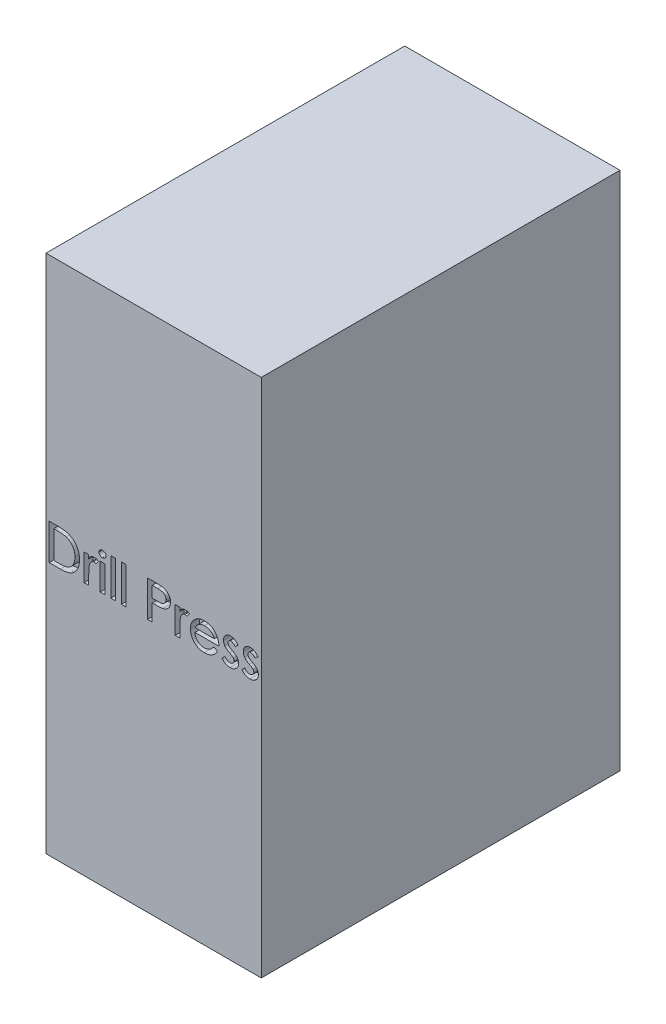
from build123d import *

# Parameters (mm, degrees)
SKETCH1_W           = 304.8
SKETCH1_H           = 508
BOSS_EXTRUDE1_DEPTH = 368.3
SKETCH3_W           = 6.512820513
SKETCH3_H           = 37.774358975
SKETCH3_W_2         = 6.512820512
SKETCH3_H_2         = 52.102564103
CUT_EXTRUDE2_DEPTH  = 12.7


with BuildPart() as part:
    # Sketch1 → Boss-Extrude1 (new, symmetric)
    with BuildSketch(Plane(origin=(0, 0, 0), x_dir=(1, 0, 0), z_dir=(0, 1, 0))):
        Rectangle(SKETCH1_W, SKETCH1_H)
    extrude(amount=BOSS_EXTRUDE1_DEPTH, both=True)

    # Sketch3 → Cut-Extrude2 (cut)
    with BuildSketch(Plane.XY.offset(254)):
        with BuildLine():
            Line((-147.913606609, -8.962248003), (-147.913606609, 41.837751997))
            Line((-147.913606609, 41.837751997), (-137.157276481, 41.837751997))
            add(Edge.make_bspline(
                [(-137.157276481, 41.837751997), (-136.251524455, 41.831438674), (-134.507480533, 41.819282241), (-131.98620406, 41.739560725), (-129.661017187, 41.602478145), (-127.526937512, 41.395851484), (-125.586109068, 41.152840361), (-123.839148556, 40.831340958), (-122.27937914, 40.484766183), (-121.324276308, 40.166046665), (-120.875225199, 40.01619751)],
                knots=[0, 0, 0, 0, 1.321377177, 2.544338591, 3.679698859, 4.71869479, 5.671952218, 6.531967125, 7.309789724, 8, 8, 8, 8], degree=3))
            add(Edge.make_bspline(
                [(-120.875225199, 40.01619751), (-120.246504354, 39.779287675), (-119.005573083, 39.311689335), (-117.247341258, 38.433946975), (-115.586235782, 37.470969925), (-114.042953471, 36.377875823), (-112.620441388, 35.161550662), (-111.294286932, 33.848560681), (-110.105408769, 32.400624766), (-109.016390087, 30.858607024), (-108.051474227, 29.220724154), (-107.216255929, 27.50848993), (-106.510843114, 25.725192129), (-105.930699182, 23.875370278), (-105.486084199, 21.955694419), (-105.157537289, 19.971387188), (-104.961222778, 17.917314029), (-104.939825233, 16.522978851), (-104.928991225, 15.816998792)],
                knots=[0, 0, 0, 0, 1.037989101, 2.048720264, 3.03347809, 4.003905725, 4.967380877, 5.923996735, 6.884742632, 7.859453364, 8.839691521, 9.819957728, 10.801471334, 11.80152298, 12.813966534, 13.844978706, 14.908869198, 16, 16, 16, 16], degree=3))
            add(Edge.make_bspline(
                [(-104.928991225, 15.816998792), (-104.938456233, 15.206088684), (-104.957153513, 13.999290213), (-105.115313102, 12.21197924), (-105.365615516, 10.474829818), (-105.723396727, 8.78895562), (-106.180863664, 7.156743133), (-106.744460466, 5.57360851), (-107.401482945, 4.037533743), (-108.167466958, 2.566016068), (-109.007104634, 1.163478166), (-109.925068884, -0.149879204), (-110.903070308, -1.374497628), (-111.943358241, -2.510499296), (-113.05560702, -3.551866105), (-114.238358109, -4.497801515), (-115.48461971, -5.357986322), (-116.806442497, -6.126485716), (-118.228527613, -6.809743899), (-119.777088066, -7.383220585), (-121.455186376, -7.868303426), (-123.261143674, -8.280735237), (-125.204446969, -8.574349194), (-127.275474655, -8.796567808), (-129.475397404, -8.946141219), (-130.986801846, -8.95677893), (-131.763846994, -8.962248003)],
                knots=[0, 0, 0, 0, 1.058131973, 2.090245403, 3.105765157, 4.096918797, 5.07359586, 6.040054961, 7.006085223, 7.965371986, 8.911666288, 9.835956746, 10.738988486, 11.624821356, 12.502036588, 13.375701924, 14.24610047, 15.122941669, 16.021834204, 16.975760622, 17.979893693, 19.046217526, 20.182340398, 21.382202726, 22.654134781, 24, 24, 24, 24], degree=3))
            Line((-131.763846994, -8.962248003), (-147.913606609, -8.962248003))
        make_face()
        with BuildLine():
            Line((-141.400786096, -3.100709541), (-136.984279686, -3.100709541))
            add(Edge.make_bspline(
                [(-136.984279686, -3.100709541), (-136.170113131, -3.097573768), (-134.605984662, -3.091549508), (-132.356962589, -3.024771967), (-130.303179802, -2.945040905), (-128.451224775, -2.797006641), (-126.797039704, -2.631795689), (-125.340590147, -2.418322257), (-124.075921644, -2.178263247), (-123.312781189, -1.952834445), (-122.961363019, -1.849026849)],
                knots=[0, 0, 0, 0, 1.383618687, 2.658126108, 3.823786659, 4.876093986, 5.815132222, 6.648351516, 7.377580062, 8, 8, 8, 8], degree=3))
            add(Edge.make_bspline(
                [(-122.961363019, -1.849026849), (-122.524541297, -1.692854728), (-121.661677931, -1.38436457), (-120.425299545, -0.810313125), (-119.260054894, -0.14814173), (-118.169851887, 0.608114475), (-117.145481958, 1.448511773), (-116.186129923, 2.372099721), (-115.308855001, 3.397869237), (-114.50823465, 4.505426537), (-113.782785461, 5.687228167), (-113.152253608, 6.939405568), (-112.618915255, 8.259423469), (-112.197875024, 9.644090706), (-111.857604363, 11.091648963), (-111.615482149, 12.604733488), (-111.472584639, 14.186037182), (-111.452186306, 15.260401881), (-111.441811737, 15.80682251)],
                knots=[0, 0, 0, 0, 0.982760408, 1.941267819, 2.884666843, 3.819923004, 4.749609063, 5.690155114, 6.638335438, 7.60609908, 8.583824457, 9.574050268, 10.573936541, 11.597196452, 12.638231748, 13.723193679, 14.842018967, 16, 16, 16, 16], degree=3))
            add(Edge.make_bspline(
                [(-111.441811737, 15.80682251), (-111.449988267, 16.380560729), (-111.466085472, 17.510084116), (-111.640786897, 19.170936502), (-111.884954616, 20.771342803), (-112.252704755, 22.306562805), (-112.73727685, 23.771834694), (-113.299581088, 25.18374816), (-113.989595415, 26.520547102), (-114.769990899, 27.790885151), (-115.641857168, 28.981520415), (-116.605568905, 30.07427316), (-117.643346575, 31.080767102), (-118.780331736, 31.970646261), (-119.98427293, 32.786315507), (-121.279921422, 33.481942634), (-122.653138602, 34.092676506), (-123.612999448, 34.41034583), (-124.101106609, 34.571886613)],
                knots=[0, 0, 0, 0, 1.129217777, 2.223100788, 3.284889252, 4.31516385, 5.326848226, 6.321524555, 7.304244934, 8.284784113, 9.254596696, 10.205833222, 11.15055266, 12.096616828, 13.045035565, 14.010353181, 14.988227444, 16, 16, 16, 16], degree=3))
            add(Edge.make_bspline(
                [(-124.101106609, 34.571886613), (-124.513738824, 34.685392925), (-125.390252887, 34.92650323), (-126.818901993, 35.204899827), (-128.428777611, 35.443548413), (-130.227324597, 35.648084297), (-132.206364341, 35.797340644), (-134.375117721, 35.89085892), (-136.725922706, 35.969422752), (-138.358000994, 35.973897539), (-139.202709173, 35.976213536)],
                knots=[0, 0, 0, 0, 0.675026783, 1.433893058, 2.294494921, 3.24250292, 4.28921909, 5.425097092, 6.667317884, 8, 8, 8, 8], degree=3))
            Line((-139.202709173, 35.976213536), (-141.400786096, 35.976213536))
            Line((-141.400786096, 35.976213536), (-141.400786096, -3.100709541))
        make_face(mode=Mode.SUBTRACT)
        with BuildLine():
            Line((-98.416170712, 28.812110972), (-91.903350199, 28.812110972))
            Line((-91.903350199, 28.812110972), (-91.903350199, 23.449210331))
            add(Edge.make_bspline(
                [(-91.903350199, 23.449210331), (-91.864051774, 23.694401604), (-91.787346822, 24.172980197), (-91.593862723, 24.860720227), (-91.326249283, 25.499232923), (-90.989876319, 26.089244796), (-90.590960268, 26.632996851), (-90.125452797, 27.127092246), (-89.595519343, 27.578451758), (-88.793775148, 28.094349226), (-87.741137478, 28.640006083), (-86.420359426, 29.113553691), (-85.068233542, 29.413547529), (-84.150548733, 29.446763001), (-83.691090584, 29.463393023)],
                knots=[0, 0, 0, 0, 0.801625561, 1.56465941, 2.301277113, 3.032414989, 3.753384473, 4.4742707, 5.220602463, 5.995500889, 7.548895402, 9.039144265, 10.517585467, 12, 12, 12, 12], degree=3))
            add(Edge.make_bspline(
                [(-83.691090584, 29.463393023), (-83.275532164, 29.438715661), (-82.402495193, 29.386871567), (-81.061470474, 29.041208929), (-79.649378773, 28.470712348), (-78.716669198, 27.960757591), (-78.226427122, 27.692719946)],
                knots=[0, 0, 0, 0, 0.858860638, 1.804360244, 2.845948385, 4, 4, 4, 4], degree=3))
            Line((-78.226427122, 27.692719946), (-81.309840584, 22.960748792))
            add(Edge.make_bspline(
                [(-81.309840584, 22.960748792), (-81.661555773, 23.06024219), (-82.304073857, 23.241998079), (-83.189725233, 23.427160945), (-83.890454361, 23.567493909), (-84.301259083, 23.591655631), (-84.474664302, 23.601854561)],
                knots=[0, 0, 0, 0, 1.354987806, 2.475310119, 3.356411532, 4, 4, 4, 4], degree=3))
            add(Edge.make_bspline(
                [(-84.474664302, 23.601854561), (-84.758801862, 23.58101822), (-85.356842549, 23.537162773), (-86.24895132, 23.19247309), (-87.164901524, 22.660671083), (-87.919526136, 22.06520602), (-88.524917722, 21.483172428), (-88.958043361, 20.949280376), (-89.378408934, 20.345048642), (-89.773036853, 19.664358413), (-90.13722657, 18.906637439), (-90.481650133, 18.080625126), (-90.812498866, 17.183200753), (-90.994913856, 16.550990311), (-91.089247635, 16.224050074)],
                knots=[0, 0, 0, 0, 0.965356871, 2.031842204, 3.216327082, 4.56533618, 5.292082419, 6.07124699, 6.900886396, 7.796081313, 8.746333432, 9.760722644, 10.841983902, 12, 12, 12, 12], degree=3))
            add(Edge.make_bspline(
                [(-91.089247635, 16.224050074), (-91.158127887, 15.953586345), (-91.312671047, 15.346760467), (-91.458167176, 14.316613221), (-91.604657375, 13.085666348), (-91.707705578, 11.648996137), (-91.802681385, 10.01070479), (-91.856704489, 8.16469545), (-91.90150288, 6.112439915), (-91.902715399, 4.674002499), (-91.903350199, 3.920925074)],
                knots=[0, 0, 0, 0, 0.541796663, 1.215601946, 2.018210726, 2.950106988, 4.012619945, 5.205915212, 6.537188929, 8, 8, 8, 8], degree=3))
            Line((-91.903350199, 3.920925074), (-91.903350199, -8.962248003))
            Line((-91.903350199, -8.962248003), (-98.416170712, -8.962248003))
            Line((-98.416170712, -8.962248003), (-98.416170712, 28.812110972))
        make_face()
        with BuildLine():
            add(Edge.make_bspline(
                [(-72.71088225, 43.791598151), (-72.319262115, 43.774448), (-71.563694209, 43.74135955), (-70.486805407, 43.475248542), (-69.524216323, 43.01760648), (-68.704194986, 42.387087766), (-68.024600793, 41.664883753), (-67.521443415, 40.884783216), (-67.218883163, 40.05772381), (-67.175945352, 39.492721974), (-67.15463225, 39.212271228)],
                knots=[0, 0, 0, 0, 1.180073081, 2.27676073, 3.320042968, 4.371717959, 5.377874923, 6.297457691, 7.154906711, 8, 8, 8, 8], degree=3))
            add(Edge.make_bspline(
                [(-67.15463225, 39.212271228), (-67.17598687, 38.935216603), (-67.219025383, 38.376835355), (-67.521388695, 37.559283131), (-68.028421999, 36.78963641), (-68.700592538, 36.06681515), (-69.527894251, 35.449111693), (-70.486292039, 34.98933841), (-71.563836869, 34.724071618), (-72.319310815, 34.690862255), (-72.71088225, 34.673649433)],
                knots=[0, 0, 0, 0, 0.838561902, 1.690053866, 2.604955955, 3.615478493, 4.665551833, 5.713360726, 6.814806749, 8, 8, 8, 8], degree=3))
            add(Edge.make_bspline(
                [(-72.71088225, 34.673649433), (-73.035238317, 34.686816735), (-73.667566895, 34.712486245), (-74.5715452, 34.987322513), (-75.413658278, 35.393193955), (-76.156887047, 35.975869808), (-76.784193391, 36.664113029), (-77.250145963, 37.447429403), (-77.521701932, 38.309417503), (-77.557164738, 38.90851643), (-77.575145071, 39.212271228)],
                knots=[0, 0, 0, 0, 1.050897616, 2.04871332, 3.044517726, 4.074156936, 5.096691018, 6.055190702, 7.01394389, 8, 8, 8, 8], degree=3))
            add(Edge.make_bspline(
                [(-77.575145071, 39.212271228), (-77.557915088, 39.522975404), (-77.524296794, 40.129206109), (-77.247488276, 40.999333633), (-76.787631142, 41.789443245), (-76.156897805, 42.479865037), (-75.410923944, 43.059508791), (-74.571695487, 43.482575788), (-73.663253029, 43.74970862), (-73.031577148, 43.777492554), (-72.71088225, 43.791598151)],
                knots=[0, 0, 0, 0, 1.003476519, 1.957934027, 2.921620235, 3.939572868, 4.964598795, 5.960849032, 6.964745478, 8, 8, 8, 8], degree=3))
        make_face()
        with Locations((-72.364888661, 9.924931485)):
            Rectangle(SKETCH3_W, SKETCH3_H)
        with Locations((-57.385401481, 17.089034049)):
            Rectangle(SKETCH3_W_2, SKETCH3_H_2)
        with Locations((-42.405914302, 17.089034049)):
            Rectangle(SKETCH3_W, SKETCH3_H_2)
        with BuildLine():
            Line((-8.539247635, 41.837751997), (1.871088904, 41.837751997))
            add(Edge.make_bspline(
                [(1.871088904, 41.837751997), (2.559724036, 41.837376842), (3.87946358, 41.836657872), (5.772111229, 41.787938069), (7.48916883, 41.745888843), (9.033173436, 41.665066635), (10.400609721, 41.554355702), (11.591968568, 41.42417291), (12.608529156, 41.277753229), (13.221594857, 41.145378164), (13.502579288, 41.084707126)],
                knots=[0, 0, 0, 0, 1.415450773, 2.712650385, 3.891531898, 4.945867971, 5.890285756, 6.71109784, 7.409261617, 8, 8, 8, 8], degree=3))
            add(Edge.make_bspline(
                [(13.502579288, 41.084707126), (13.898131482, 40.982988643), (14.678434715, 40.782329256), (15.793907219, 40.368710915), (16.852339938, 39.898718935), (17.850119189, 39.364087161), (18.777053057, 38.746616127), (19.653139668, 38.075743517), (20.451431917, 37.317537543), (21.19927864, 36.508780457), (21.855443662, 35.6309996), (22.443369417, 34.713896433), (22.93067045, 33.744150288), (23.33114945, 32.725368292), (23.644218367, 31.662862161), (23.869413357, 30.553246588), (24.004730594, 29.398954794), (24.018063945, 28.612347579), (24.024854929, 28.211710331)],
                knots=[0, 0, 0, 0, 1.085641105, 2.141637125, 3.15936318, 4.164535163, 5.147931294, 6.118832473, 7.09541784, 8.072503165, 9.045079613, 10.006206652, 10.966486436, 11.926469503, 12.914201526, 13.908586125, 14.934794539, 16, 16, 16, 16], degree=3))
            add(Edge.make_bspline(
                [(24.024854929, 28.211710331), (24.017914955, 27.811091749), (24.004230679, 27.021150102), (23.869767946, 25.85995779), (23.644368877, 24.748037131), (23.340488916, 23.68047601), (22.941123231, 22.663913765), (22.463914297, 21.689768222), (21.887060209, 20.769076223), (21.228513249, 19.895447181), (20.48482581, 19.082306906), (19.666775982, 18.332741749), (18.763610754, 17.659842571), (17.784593134, 17.051531525), (16.733134528, 16.497141551), (15.598657168, 16.020305327), (14.386222504, 15.613995449), (13.544765494, 15.397949353), (13.11588057, 15.287832126)],
                knots=[0, 0, 0, 0, 1.042501879, 2.055610221, 3.037454288, 3.993184118, 4.940927036, 5.876790881, 6.812738028, 7.76458517, 8.720845088, 9.677105007, 10.648370915, 11.647960469, 12.67482723, 13.739162042, 14.847666245, 16, 16, 16, 16], degree=3))
            add(Edge.make_bspline(
                [(13.11588057, 15.287832126), (12.801112421, 15.219588124), (12.114452203, 15.070715244), (10.974980878, 14.915802353), (9.647264183, 14.788888564), (8.127105781, 14.678471215), (6.420736787, 14.585719655), (4.520588466, 14.530506876), (2.430994505, 14.485954256), (0.972213215, 14.484607401), (0.212354929, 14.483905844)],
                knots=[0, 0, 0, 0, 0.596754895, 1.30180848, 2.129432098, 3.068723067, 4.126429569, 5.296393252, 6.591729958, 8, 8, 8, 8], degree=3))
            Line((0.212354929, 14.483905844), (-2.026427122, 14.483905844))
            Line((-2.026427122, 14.483905844), (-2.026427122, -8.962248003))
            Line((-2.026427122, -8.962248003), (-8.539247635, -8.962248003))
            Line((-8.539247635, -8.962248003), (-8.539247635, 41.837751997))
        make_face()
        with BuildLine():
            Line((-2.026427122, 35.976213536), (-2.026427122, 20.325091741))
            Line((-2.026427122, 20.325091741), (5.300495955, 20.243681485))
            add(Edge.make_bspline(
                [(5.300495955, 20.243681485), (5.714346897, 20.249138658), (6.511707346, 20.259652913), (7.662360786, 20.296159639), (8.720717579, 20.370357096), (9.688822121, 20.456892207), (10.568630103, 20.578214838), (11.356180699, 20.729631354), (12.058189121, 20.899756009), (12.860945747, 21.167229625), (13.759506393, 21.5848685), (14.714774515, 22.222099042), (15.55681043, 22.984179807), (16.252205109, 23.881147383), (16.811829947, 24.869429149), (17.227813215, 25.925719909), (17.463267229, 27.048063131), (17.495640967, 27.813786308), (17.512034416, 28.201534049)],
                knots=[0, 0, 0, 0, 1.196816259, 2.305888068, 3.328295896, 4.264290022, 5.116006351, 5.89509982, 6.582615619, 7.202969204, 8.339503699, 9.435837163, 10.511976311, 11.608836183, 12.702577786, 13.786378287, 14.879063815, 16, 16, 16, 16], degree=3))
            add(Edge.make_bspline(
                [(17.512034416, 28.201534049), (17.495522549, 28.575750387), (17.46277188, 29.317994422), (17.226087085, 30.409646522), (16.809911835, 31.445112337), (16.249375483, 32.419511377), (15.568218508, 33.310126707), (14.761355666, 34.076276101), (13.848210278, 34.702433574), (12.995718806, 35.103476371), (12.235591499, 35.364467601), (11.565648565, 35.517781731), (10.808817738, 35.661128313), (9.960399313, 35.784016658), (9.019603977, 35.872645756), (7.987565819, 35.929496523), (6.868026201, 35.974048016), (6.090904931, 35.975473174), (5.687194673, 35.976213536)],
                knots=[0, 0, 0, 0, 1.113934591, 2.209447376, 3.306634974, 4.424089692, 5.547326231, 6.633252657, 7.723023745, 8.829884498, 9.427152571, 10.113060991, 10.873719268, 11.720735618, 12.664423995, 13.686322671, 14.798057257, 16, 16, 16, 16], degree=3))
            Line((5.687194673, 35.976213536), (-2.026427122, 35.976213536))
        make_face(mode=Mode.SUBTRACT)
        with BuildLine():
            Line((30.537675442, 28.812110972), (37.050495955, 28.812110972))
            Line((37.050495955, 28.812110972), (37.050495955, 23.449210331))
            add(Edge.make_bspline(
                [(37.050495955, 23.449210331), (37.08979438, 23.694401604), (37.166499332, 24.172980197), (37.35998343, 24.860720227), (37.62759687, 25.499232923), (37.963969834, 26.089244796), (38.362885886, 26.632996851), (38.828393357, 27.127092246), (39.358326811, 27.578451758), (40.160071005, 28.094349226), (41.212708676, 28.640006083), (42.533486728, 29.113553691), (43.885612612, 29.413547529), (44.803297421, 29.446763001), (45.26275557, 29.463393023)],
                knots=[0, 0, 0, 0, 0.801625561, 1.56465941, 2.301277113, 3.032414989, 3.753384473, 4.4742707, 5.220602463, 5.995500889, 7.548895402, 9.039144265, 10.517585467, 12, 12, 12, 12], degree=3))
            add(Edge.make_bspline(
                [(45.26275557, 29.463393023), (45.678313989, 29.438715661), (46.551350961, 29.386871567), (47.892375679, 29.041208929), (49.304467381, 28.470712348), (50.237176956, 27.960757591), (50.727419032, 27.692719946)],
                knots=[0, 0, 0, 0, 0.858860638, 1.804360244, 2.845948385, 4, 4, 4, 4], degree=3))
            Line((50.727419032, 27.692719946), (47.64400557, 22.960748792))
            add(Edge.make_bspline(
                [(47.64400557, 22.960748792), (47.29229038, 23.06024219), (46.649772297, 23.241998079), (45.764120921, 23.427160945), (45.063391793, 23.567493909), (44.652587071, 23.591655631), (44.479181852, 23.601854561)],
                knots=[0, 0, 0, 0, 1.354987806, 2.475310119, 3.356411532, 4, 4, 4, 4], degree=3))
            add(Edge.make_bspline(
                [(44.479181852, 23.601854561), (44.195044292, 23.58101822), (43.597003605, 23.537162773), (42.704894834, 23.19247309), (41.78894463, 22.660671083), (41.034320018, 22.06520602), (40.428928431, 21.483172428), (39.995802793, 20.949280376), (39.575437219, 20.345048642), (39.180809301, 19.664358413), (38.816619584, 18.906637439), (38.472196021, 18.080625126), (38.141347288, 17.183200753), (37.958932298, 16.550990311), (37.864598519, 16.224050074)],
                knots=[0, 0, 0, 0, 0.965356871, 2.031842204, 3.216327082, 4.56533618, 5.292082419, 6.07124699, 6.900886396, 7.796081313, 8.746333432, 9.760722644, 10.841983902, 12, 12, 12, 12], degree=3))
            add(Edge.make_bspline(
                [(37.864598519, 16.224050074), (37.795718267, 15.953586345), (37.641175107, 15.346760467), (37.495678977, 14.316613221), (37.349188779, 13.085666348), (37.246140576, 11.648996137), (37.151164769, 10.01070479), (37.097141665, 8.16469545), (37.052343274, 6.112439915), (37.051130755, 4.674002499), (37.050495955, 3.920925074)],
                knots=[0, 0, 0, 0, 0.541796663, 1.215601946, 2.018210726, 2.950106988, 4.012619945, 5.205915212, 6.537188929, 8, 8, 8, 8], degree=3))
            Line((37.050495955, 3.920925074), (37.050495955, -8.962248003))
            Line((37.050495955, -8.962248003), (30.537675442, -8.962248003))
            Line((30.537675442, -8.962248003), (30.537675442, 28.812110972))
        make_face()
        with BuildLine():
            Line((85.031665827, 4.063393023), (90.45562416, 1.4684411))
            add(Edge.make_bspline(
                [(90.45562416, 1.4684411), (90.112715276, 0.845247373), (89.444930742, -0.368366951), (88.30544428, -2.0442293), (87.068813232, -3.518056468), (85.747057277, -4.806160003), (84.323686399, -5.90823587), (82.824319293, -6.885959262), (81.217154512, -7.705775238), (79.522819351, -8.4065268), (77.71907257, -8.945781146), (75.808134856, -9.328875213), (73.78610126, -9.567516479), (72.400181557, -9.597948293), (71.690560057, -9.613530054)],
                knots=[0, 0, 0, 0, 1.110387997, 2.162381809, 3.158716456, 4.110235088, 5.03849693, 5.965639636, 6.901458115, 7.851707839, 8.825366416, 9.836184406, 10.892078622, 12, 12, 12, 12], degree=3))
            add(Edge.make_bspline(
                [(71.690560057, -9.613530054), (70.939866473, -9.598064437), (69.473491456, -9.567854517), (67.342046096, -9.270900201), (65.330828972, -8.821531417), (63.447125732, -8.170704102), (61.698207167, -7.31590794), (60.063204527, -6.295257928), (58.561333477, -5.077032581), (57.206936059, -3.681746101), (56.0038226, -2.174819708), (54.928555939, -0.615621314), (54.049066215, 1.011492543), (53.306248338, 2.675116836), (52.734451102, 4.393194254), (52.329327874, 6.158193082), (52.074920838, 7.973853265), (52.045087571, 9.201577757), (52.029983134, 9.823168664)],
                knots=[0, 0, 0, 0, 1.164566152, 2.274817246, 3.333639364, 4.359360714, 5.360157823, 6.349126428, 7.344925074, 8.35392925, 9.361228562, 10.335284257, 11.289572886, 12.22779236, 13.160187688, 14.095091993, 15.035554391, 16, 16, 16, 16], degree=3))
            add(Edge.make_bspline(
                [(52.029983134, 9.823168664), (52.043207978, 10.403923666), (52.069439132, 11.555837056), (52.293165829, 13.257043768), (52.634225175, 14.913196044), (53.125513593, 16.517522587), (53.761341555, 18.072847094), (54.536938353, 19.581332874), (55.452833289, 21.042558129), (56.160522616, 21.958892775), (56.517723519, 22.421405844)],
                knots=[0, 0, 0, 0, 1.021096707, 2.025320431, 3.012923591, 3.992437812, 4.971861174, 5.964497656, 6.972595394, 8, 8, 8, 8], degree=3))
            add(Edge.make_bspline(
                [(56.517723519, 22.421405844), (57.000769183, 22.98257954), (57.952870397, 24.088674051), (59.575437461, 25.527334375), (61.314305842, 26.751411435), (63.180932557, 27.739523153), (65.161477999, 28.524617958), (67.267251915, 29.067433026), (69.492032896, 29.400485773), (71.014341833, 29.442117163), (71.792322878, 29.463393023)],
                knots=[0, 0, 0, 0, 1.018725525, 2.007946416, 2.977291296, 3.940674949, 4.909614547, 5.904411593, 6.929042575, 8, 8, 8, 8], degree=3))
            add(Edge.make_bspline(
                [(71.792322878, 29.463393023), (72.631484549, 29.444057141), (74.269835472, 29.406306418), (76.653329977, 29.049039046), (78.90147065, 28.484711685), (81.00861285, 27.676737598), (82.979016608, 26.640643838), (84.812156266, 25.380660834), (86.511531972, 23.889392981), (87.494526139, 22.733005127), (87.992963904, 22.146646228)],
                knots=[0, 0, 0, 0, 1.092510559, 2.132980742, 3.131821249, 4.106721871, 5.065344059, 6.025034973, 6.998572742, 8, 8, 8, 8], degree=3))
            add(Edge.make_bspline(
                [(87.992963904, 22.146646228), (88.341952272, 21.692066644), (89.037692905, 20.785820144), (89.909315273, 19.300861233), (90.667390686, 17.741308379), (91.291887716, 16.086855248), (91.761481114, 14.339477111), (92.12470992, 12.511676429), (92.334159061, 10.594471642), (92.377319658, 9.287689783), (92.399294032, 8.622367382)],
                knots=[0, 0, 0, 0, 0.947891001, 1.889708495, 2.844047414, 3.816063809, 4.811874475, 5.836031954, 6.898258033, 8, 8, 8, 8], degree=3))
            Line((92.399294032, 8.622367382), (58.532627365, 8.622367382))
            add(Edge.make_bspline(
                [(58.532627365, 8.622367382), (58.550098558, 8.190628823), (58.584408012, 7.342792354), (58.800606512, 6.104577533), (59.100597084, 4.916796045), (59.520986051, 3.781291092), (60.053174694, 2.69734571), (60.695056973, 1.665670505), (61.456342101, 0.694103851), (62.315594586, -0.214629461), (63.25311685, -1.041432696), (64.243650575, -1.767863047), (65.27973704, -2.388652237), (66.367849337, -2.881325516), (67.497522761, -3.276684649), (68.67224058, -3.543638974), (69.890210259, -3.729990374), (70.719691883, -3.744580365), (71.141040827, -3.751991592)],
                knots=[0, 0, 0, 0, 1.056285998, 2.074305788, 3.068874036, 4.051103373, 5.031155672, 6.019259974, 7.018838325, 8.046424154, 9.075617995, 10.073437039, 11.048590896, 12.025474346, 12.991505956, 13.972050267, 14.969869311, 16, 16, 16, 16], degree=3))
            add(Edge.make_bspline(
                [(71.141040827, -3.751991592), (71.592772506, -3.743497616), (72.492432899, -3.72658117), (73.824390878, -3.551028794), (75.137296596, -3.304971038), (76.409022769, -2.932094828), (77.629942885, -2.49563562), (78.761924655, -1.974672686), (79.795036169, -1.395288565), (80.768868473, -0.725027155), (81.739049786, 0.11533071), (82.761157781, 1.195952892), (83.876466414, 2.535234748), (84.629035958, 3.530773149), (85.031665827, 4.063393023)],
                knots=[0, 0, 0, 0, 0.974501181, 1.940798391, 2.895710587, 3.855187413, 4.797895034, 5.692306932, 6.541458453, 7.351844759, 8.239729442, 9.306468335, 10.558942083, 12, 12, 12, 12], degree=3))
        make_face()
        with BuildLine():
            add(Edge.make_bspline(
                [(85.896649801, 14.483905844), (85.731615416, 14.904634428), (85.402466066, 15.743747686), (84.768765567, 16.934957229), (84.018433234, 18.04741683), (83.172457535, 19.098089807), (82.187682308, 20.064763152), (81.04821094, 20.927477672), (79.766606286, 21.709725621), (78.342500775, 22.365671706), (76.832156863, 22.912927029), (75.265544434, 23.313982832), (73.65858455, 23.55313668), (72.573299658, 23.585530105), (72.026377365, 23.601854561)],
                knots=[0, 0, 0, 0, 0.917468198, 1.829825112, 2.733739057, 3.639830069, 4.565591991, 5.528900948, 6.536885056, 7.609579627, 8.708054817, 9.795976896, 10.889296829, 12, 12, 12, 12], degree=3))
            add(Edge.make_bspline(
                [(72.026377365, 23.601854561), (71.608775269, 23.591319368), (70.78133165, 23.570444764), (69.558596364, 23.427003023), (68.37321895, 23.18336083), (67.225751353, 22.834571564), (66.117052737, 22.385388279), (65.040828, 21.842204185), (64.001107686, 21.203444586), (63.348828275, 20.707247452), (63.02036775, 20.457383408)],
                knots=[0, 0, 0, 0, 1.030056501, 2.040970785, 3.032161429, 4.011555994, 4.995123754, 5.979296403, 6.982458509, 8, 8, 8, 8], degree=3))
            add(Edge.make_bspline(
                [(63.02036775, 20.457383408), (62.6033004, 20.090242902), (61.749744518, 19.338865607), (60.690147607, 17.92846871), (59.736929867, 16.311455752), (59.25926347, 15.109061202), (59.010912622, 14.483905844)],
                knots=[0, 0, 0, 0, 0.913853049, 1.870260628, 2.892694598, 4, 4, 4, 4], degree=3))
            Line((59.010912622, 14.483905844), (85.896649801, 14.483905844))
        make_face(mode=Mode.SUBTRACT)
        with BuildLine():
            Line((119.763316468, 23.469562895), (115.601217109, 19.694162254))
            add(Edge.make_bspline(
                [(115.601217109, 19.694162254), (115.296579007, 20.003715935), (114.710261189, 20.599494458), (113.8032498, 21.387446878), (112.937580067, 22.07131864), (112.092503844, 22.62214331), (111.276596714, 23.056856198), (110.488715941, 23.366053467), (109.728985489, 23.563433882), (109.228533996, 23.589334929), (108.986633775, 23.601854561)],
                knots=[0, 0, 0, 0, 1.323954473, 2.548132, 3.661338868, 4.685637623, 5.620299102, 6.475132344, 7.262933916, 8, 8, 8, 8], degree=3))
            add(Edge.make_bspline(
                [(108.986633775, 23.601854561), (108.774280107, 23.588831346), (108.344425852, 23.562469264), (107.720942313, 23.31883026), (107.123219568, 22.94027541), (106.550782362, 22.440141169), (106.050321914, 21.816383995), (105.692843852, 21.079089085), (105.470106551, 20.253138396), (105.447113928, 19.671925491), (105.435111339, 19.368521228)],
                knots=[0, 0, 0, 0, 0.832490187, 1.685157841, 2.595972223, 3.607628721, 4.662023247, 5.718189086, 6.808851023, 8, 8, 8, 8], degree=3))
            add(Edge.make_bspline(
                [(105.435111339, 19.368521228), (105.44569555, 19.095831432), (105.466327408, 18.564275725), (105.660704804, 17.803639668), (105.948105767, 17.090358093), (106.249957618, 16.683300296), (106.401858134, 16.478457126)],
                knots=[0, 0, 0, 0, 1.051456026, 2.049608974, 3.018507243, 4, 4, 4, 4], degree=3))
            add(Edge.make_bspline(
                [(106.401858134, 16.478457126), (106.665633839, 16.18551422), (107.241567833, 15.545895883), (108.360832761, 14.687287014), (109.726919846, 13.778849185), (110.755857304, 13.210772277), (111.306826083, 12.906582126)],
                knots=[0, 0, 0, 0, 0.773884963, 1.689718389, 2.762905336, 4, 4, 4, 4], degree=3))
            add(Edge.make_bspline(
                [(111.306826083, 12.906582126), (111.742529554, 12.66843859), (112.579995189, 12.210702904), (113.761532753, 11.50868334), (114.827108694, 10.82271959), (115.783675091, 10.158417433), (116.619221537, 9.498155156), (117.334222171, 8.853974871), (117.947375616, 8.237081529), (118.281588666, 7.801528631), (118.440399801, 7.594562895)],
                knots=[0, 0, 0, 0, 1.33001518, 2.556422155, 3.680542608, 4.724184501, 5.674971885, 6.530695486, 7.30181686, 8, 8, 8, 8], degree=3))
            add(Edge.make_bspline(
                [(118.440399801, 7.594562895), (118.743773389, 7.121031247), (119.337202291, 6.194756263), (119.957137804, 4.692103449), (120.344917374, 3.153644502), (120.391362257, 2.111792497), (120.414598519, 1.590556485)],
                knots=[0, 0, 0, 0, 1.049962625, 2.053831286, 3.026336549, 4, 4, 4, 4], degree=3))
            add(Edge.make_bspline(
                [(120.414598519, 1.590556485), (120.406107356, 1.220142466), (120.389350904, 0.48916784), (120.217608075, -0.584133372), (119.955966744, -1.622723242), (119.573206387, -2.622814579), (119.095539667, -3.592161628), (118.508815483, -4.526080188), (117.814794872, -5.423436495), (117.015551524, -6.269973705), (116.137911291, -7.047956735), (115.194493209, -7.739260732), (114.187606792, -8.319329307), (113.113803201, -8.787808757), (111.986760795, -9.173311703), (110.785343261, -9.414364726), (109.531135367, -9.589891011), (108.67183073, -9.605546049), (108.233588904, -9.613530054)],
                knots=[0, 0, 0, 0, 0.963489602, 1.901349341, 2.822262455, 3.747230613, 4.683134612, 5.631288318, 6.613293617, 7.631511985, 8.657397281, 9.662358437, 10.671075458, 11.675221639, 12.708377436, 13.76481686, 14.860065804, 16, 16, 16, 16], degree=3))
            add(Edge.make_bspline(
                [(108.233588904, -9.613530054), (107.696550513, -9.595340377), (106.62617467, -9.559086375), (105.042424145, -9.28453954), (103.491969978, -8.845560247), (101.98985165, -8.227308657), (100.555052885, -7.426354215), (99.238001789, -6.411729864), (98.010903901, -5.233758737), (97.319545049, -4.318540012), (96.968444673, -3.853754413)],
                knots=[0, 0, 0, 0, 0.979216887, 1.951685614, 2.923149898, 3.913640395, 4.908296688, 5.910698089, 6.938966812, 8, 8, 8, 8], degree=3))
            Line((96.968444673, -3.853754413), (100.804903006, 0.155700715))
            add(Edge.make_bspline(
                [(100.804903006, 0.155700715), (101.130038071, -0.153930006), (101.757203772, -0.751188774), (102.725395961, -1.543421939), (103.661354694, -2.219946496), (104.570236848, -2.777419727), (105.456396799, -3.208152469), (106.318251553, -3.51931079), (107.156404914, -3.713759235), (107.71026855, -3.739495873), (107.979181852, -3.751991592)],
                knots=[0, 0, 0, 0, 1.288506075, 2.485449601, 3.588003455, 4.601705531, 5.542438646, 6.411005369, 7.228507225, 8, 8, 8, 8], degree=3))
            add(Edge.make_bspline(
                [(107.979181852, -3.751991592), (108.377752522, -3.73180368), (109.155017467, -3.692434609), (110.277082059, -3.402192095), (111.300006735, -2.906233408), (112.19724597, -2.224043391), (112.945388181, -1.423351679), (113.503387237, -0.535559151), (113.835341319, 0.431594189), (113.879443591, 1.099612336), (113.901778006, 1.437912254)],
                knots=[0, 0, 0, 0, 1.096025125, 2.137392371, 3.164312155, 4.204088696, 5.221248568, 6.164137697, 7.070276657, 8, 8, 8, 8], degree=3))
            add(Edge.make_bspline(
                [(113.901778006, 1.437912254), (113.887964287, 1.714039174), (113.86079804, 2.257074138), (113.647495508, 3.046772877), (113.300107499, 3.794806056), (112.964226774, 4.235192986), (112.792563263, 4.460268023)],
                knots=[0, 0, 0, 0, 1.00762038, 1.981599971, 2.968426558, 4, 4, 4, 4], degree=3))
            add(Edge.make_bspline(
                [(112.792563263, 4.460268023), (112.682786929, 4.581165425), (112.442055345, 4.84628471), (111.997387188, 5.228521219), (111.461572579, 5.639008836), (110.835387949, 6.085403934), (110.099911178, 6.532852242), (109.277356101, 7.027137426), (108.348995205, 7.529889052), (107.697962859, 7.873362952), (107.358428647, 8.052495587)],
                knots=[0, 0, 0, 0, 0.598311898, 1.312054841, 2.145484848, 3.073753233, 4.129800786, 5.300877464, 6.592321185, 8, 8, 8, 8], degree=3))
            add(Edge.make_bspline(
                [(107.358428647, 8.052495587), (106.969877508, 8.266403516), (106.215864557, 8.681508072), (105.150986161, 9.336774339), (104.166928903, 9.970859798), (103.292000269, 10.622656794), (102.513677938, 11.278860668), (101.824877814, 11.924795139), (101.219329988, 12.564298185), (100.89184357, 13.021549166), (100.733669032, 13.242399433)],
                knots=[0, 0, 0, 0, 1.253912045, 2.433311408, 3.534624239, 4.562802555, 5.515759338, 6.411389838, 7.23270809, 8, 8, 8, 8], degree=3))
            add(Edge.make_bspline(
                [(100.733669032, 13.242399433), (100.452310855, 13.684994352), (99.891369462, 14.567392059), (99.347586904, 16.050572585), (98.978916382, 17.610188718), (98.941387663, 18.687851067), (98.922290827, 19.236229561)],
                knots=[0, 0, 0, 0, 0.987528248, 1.968826629, 2.966418566, 4, 4, 4, 4], degree=3))
            add(Edge.make_bspline(
                [(98.922290827, 19.236229561), (98.927474998, 19.596456377), (98.937642485, 20.302953456), (99.095063655, 21.331874527), (99.296539998, 22.321606063), (99.622867897, 23.257426578), (100.011489129, 24.162108031), (100.519867364, 25.001481124), (101.091538898, 25.809836622), (101.759605043, 26.554743088), (102.500654648, 27.229979551), (103.28062072, 27.836140286), (104.114590386, 28.340078029), (104.997190698, 28.745618673), (105.921284604, 29.077635619), (106.896459426, 29.292476934), (107.909779027, 29.447421075), (108.602698104, 29.457998341), (108.956104929, 29.463393023)],
                knots=[0, 0, 0, 0, 1.077691122, 2.11362841, 3.112019185, 4.098344371, 5.07626173, 6.055497571, 7.031037172, 8.038433535, 9.045112416, 10.030652415, 10.992446082, 11.956062447, 12.936088526, 13.926799257, 14.942613481, 16, 16, 16, 16], degree=3))
            add(Edge.make_bspline(
                [(108.956104929, 29.463393023), (109.412155581, 29.446388713), (110.333059321, 29.412051886), (111.706930884, 29.107906367), (113.076447636, 28.638391382), (114.440093641, 27.98010241), (115.786166346, 27.122328399), (117.134151662, 26.087256439), (118.478691764, 24.864979747), (119.326004436, 23.944590798), (119.763316468, 23.469562895)],
                knots=[0, 0, 0, 0, 0.858658356, 1.733890061, 2.639692681, 3.583355905, 4.58026951, 5.642917418, 6.783470838, 8, 8, 8, 8], degree=3))
        make_face()
        with BuildLine():
            Line((147.768444673, 23.469562895), (143.606345314, 19.694162254))
            add(Edge.make_bspline(
                [(143.606345314, 19.694162254), (143.301707212, 20.003715935), (142.715389395, 20.599494458), (141.808378005, 21.387446878), (140.942708273, 22.07131864), (140.097632049, 22.62214331), (139.281724919, 23.056856198), (138.493844146, 23.366053467), (137.734113694, 23.563433882), (137.233662201, 23.589334929), (136.991761981, 23.601854561)],
                knots=[0, 0, 0, 0, 1.323954473, 2.548132, 3.661338868, 4.685637623, 5.620299102, 6.475132344, 7.262933916, 8, 8, 8, 8], degree=3))
            add(Edge.make_bspline(
                [(136.991761981, 23.601854561), (136.779408312, 23.588831346), (136.349554057, 23.562469264), (135.726070518, 23.31883026), (135.128347773, 22.94027541), (134.555910567, 22.440141169), (134.055450119, 21.816383995), (133.697972057, 21.079089085), (133.475234756, 20.253138396), (133.452242134, 19.671925491), (133.440239545, 19.368521228)],
                knots=[0, 0, 0, 0, 0.832490187, 1.685157841, 2.595972223, 3.607628721, 4.662023247, 5.718189086, 6.808851023, 8, 8, 8, 8], degree=3))
            add(Edge.make_bspline(
                [(133.440239545, 19.368521228), (133.450823755, 19.095831432), (133.471455613, 18.564275725), (133.665833009, 17.803639668), (133.953233972, 17.090358093), (134.255085823, 16.683300296), (134.406986339, 16.478457126)],
                knots=[0, 0, 0, 0, 1.051456026, 2.049608974, 3.018507243, 4, 4, 4, 4], degree=3))
            add(Edge.make_bspline(
                [(134.406986339, 16.478457126), (134.670762044, 16.18551422), (135.246696038, 15.545895883), (136.365960966, 14.687287014), (137.732048051, 13.778849185), (138.760985509, 13.210772277), (139.311954288, 12.906582126)],
                knots=[0, 0, 0, 0, 0.773884963, 1.689718389, 2.762905336, 4, 4, 4, 4], degree=3))
            add(Edge.make_bspline(
                [(139.311954288, 12.906582126), (139.74765776, 12.66843859), (140.585123394, 12.210702904), (141.766660958, 11.50868334), (142.832236899, 10.82271959), (143.788803296, 10.158417433), (144.624349742, 9.498155156), (145.339350376, 8.853974871), (145.952503821, 8.237081529), (146.286716871, 7.801528631), (146.445528006, 7.594562895)],
                knots=[0, 0, 0, 0, 1.33001518, 2.556422155, 3.680542608, 4.724184501, 5.674971885, 6.530695486, 7.30181686, 8, 8, 8, 8], degree=3))
            add(Edge.make_bspline(
                [(146.445528006, 7.594562895), (146.748901595, 7.121031247), (147.342330496, 6.194756263), (147.96226601, 4.692103449), (148.350045579, 3.153644502), (148.396490462, 2.111792497), (148.419726724, 1.590556485)],
                knots=[0, 0, 0, 0, 1.049962625, 2.053831286, 3.026336549, 4, 4, 4, 4], degree=3))
            add(Edge.make_bspline(
                [(148.419726724, 1.590556485), (148.411235561, 1.220142466), (148.394479109, 0.48916784), (148.22273628, -0.584133372), (147.96109495, -1.622723242), (147.578334593, -2.622814579), (147.100667872, -3.592161628), (146.513943688, -4.526080188), (145.819923077, -5.423436495), (145.020679729, -6.269973705), (144.143039496, -7.047956735), (143.199621415, -7.739260732), (142.192734998, -8.319329307), (141.118931406, -8.787808757), (139.991889, -9.173311703), (138.790471466, -9.414364726), (137.536263572, -9.589891011), (136.676958935, -9.605546049), (136.238717109, -9.613530054)],
                knots=[0, 0, 0, 0, 0.963489602, 1.901349341, 2.822262455, 3.747230613, 4.683134612, 5.631288318, 6.613293617, 7.631511985, 8.657397281, 9.662358437, 10.671075458, 11.675221639, 12.708377436, 13.76481686, 14.860065804, 16, 16, 16, 16], degree=3))
            add(Edge.make_bspline(
                [(136.238717109, -9.613530054), (135.701678718, -9.595340377), (134.631302875, -9.559086375), (133.04755235, -9.28453954), (131.497098183, -8.845560247), (129.994979855, -8.227308657), (128.56018109, -7.426354215), (127.243129994, -6.411729864), (126.016032106, -5.233758737), (125.324673254, -4.318540012), (124.973572878, -3.853754413)],
                knots=[0, 0, 0, 0, 0.979216887, 1.951685614, 2.923149898, 3.913640395, 4.908296688, 5.910698089, 6.938966812, 8, 8, 8, 8], degree=3))
            Line((124.973572878, -3.853754413), (128.810031211, 0.155700715))
            add(Edge.make_bspline(
                [(128.810031211, 0.155700715), (129.135166276, -0.153930006), (129.762331977, -0.751188774), (130.730524166, -1.543421939), (131.666482899, -2.219946496), (132.575365053, -2.777419727), (133.461525004, -3.208152469), (134.323379759, -3.51931079), (135.16153312, -3.713759235), (135.715396755, -3.739495873), (135.984310057, -3.751991592)],
                knots=[0, 0, 0, 0, 1.288506075, 2.485449601, 3.588003455, 4.601705531, 5.542438646, 6.411005369, 7.228507225, 8, 8, 8, 8], degree=3))
            add(Edge.make_bspline(
                [(135.984310057, -3.751991592), (136.382880727, -3.73180368), (137.160145673, -3.692434609), (138.282210264, -3.402192095), (139.30513494, -2.906233408), (140.202374175, -2.224043391), (140.950516387, -1.423351679), (141.508515442, -0.535559151), (141.840469524, 0.431594189), (141.884571796, 1.099612336), (141.906906211, 1.437912254)],
                knots=[0, 0, 0, 0, 1.096025125, 2.137392371, 3.164312155, 4.204088696, 5.221248568, 6.164137697, 7.070276657, 8, 8, 8, 8], degree=3))
            add(Edge.make_bspline(
                [(141.906906211, 1.437912254), (141.893092493, 1.714039174), (141.865926245, 2.257074138), (141.652623713, 3.046772877), (141.305235704, 3.794806056), (140.969354979, 4.235192986), (140.797691468, 4.460268023)],
                knots=[0, 0, 0, 0, 1.00762038, 1.981599971, 2.968426558, 4, 4, 4, 4], degree=3))
            add(Edge.make_bspline(
                [(140.797691468, 4.460268023), (140.687915134, 4.581165425), (140.447183551, 4.84628471), (140.002515393, 5.228521219), (139.466700784, 5.639008836), (138.840516154, 6.085403934), (138.105039383, 6.532852242), (137.282484306, 7.027137426), (136.35412341, 7.529889052), (135.703091064, 7.873362952), (135.363556852, 8.052495587)],
                knots=[0, 0, 0, 0, 0.598311898, 1.312054841, 2.145484848, 3.073753233, 4.129800786, 5.300877464, 6.592321185, 8, 8, 8, 8], degree=3))
            add(Edge.make_bspline(
                [(135.363556852, 8.052495587), (134.975005713, 8.266403516), (134.220992762, 8.681508072), (133.156114366, 9.336774339), (132.172057109, 9.970859798), (131.297128474, 10.622656794), (130.518806144, 11.278860668), (129.830006019, 11.924795139), (129.224458193, 12.564298185), (128.896971775, 13.021549166), (128.738797237, 13.242399433)],
                knots=[0, 0, 0, 0, 1.253912045, 2.433311408, 3.534624239, 4.562802555, 5.515759338, 6.411389838, 7.23270809, 8, 8, 8, 8], degree=3))
            add(Edge.make_bspline(
                [(128.738797237, 13.242399433), (128.45743906, 13.684994352), (127.896497667, 14.567392059), (127.352715109, 16.050572585), (126.984044587, 17.610188718), (126.946515869, 18.687851067), (126.927419032, 19.236229561)],
                knots=[0, 0, 0, 0, 0.987528248, 1.968826629, 2.966418566, 4, 4, 4, 4], degree=3))
            add(Edge.make_bspline(
                [(126.927419032, 19.236229561), (126.932603203, 19.596456377), (126.94277069, 20.302953456), (127.100191861, 21.331874527), (127.301668203, 22.321606063), (127.627996102, 23.257426578), (128.016617334, 24.162108031), (128.524995569, 25.001481124), (129.096667103, 25.809836622), (129.764733248, 26.554743088), (130.505782854, 27.229979551), (131.285748925, 27.836140286), (132.119718591, 28.340078029), (133.002318903, 28.745618673), (133.926412809, 29.077635619), (134.901587631, 29.292476934), (135.914907232, 29.447421075), (136.60782631, 29.457998341), (136.961233134, 29.463393023)],
                knots=[0, 0, 0, 0, 1.077691122, 2.11362841, 3.112019185, 4.098344371, 5.07626173, 6.055497571, 7.031037172, 8.038433535, 9.045112416, 10.030652415, 10.992446082, 11.956062447, 12.936088526, 13.926799257, 14.942613481, 16, 16, 16, 16], degree=3))
            add(Edge.make_bspline(
                [(136.961233134, 29.463393023), (137.417283786, 29.446388713), (138.338187526, 29.412051886), (139.712059089, 29.107906367), (141.081575841, 28.638391382), (142.445221846, 27.98010241), (143.791294551, 27.122328399), (145.139279867, 26.087256439), (146.48381997, 24.864979747), (147.331132641, 23.944590798), (147.768444673, 23.469562895)],
                knots=[0, 0, 0, 0, 0.858658356, 1.733890061, 2.639692681, 3.583355905, 4.58026951, 5.642917418, 6.783470838, 8, 8, 8, 8], degree=3))
        make_face()
    extrude(amount=-CUT_EXTRUDE2_DEPTH, mode=Mode.SUBTRACT)


solid = part.part
